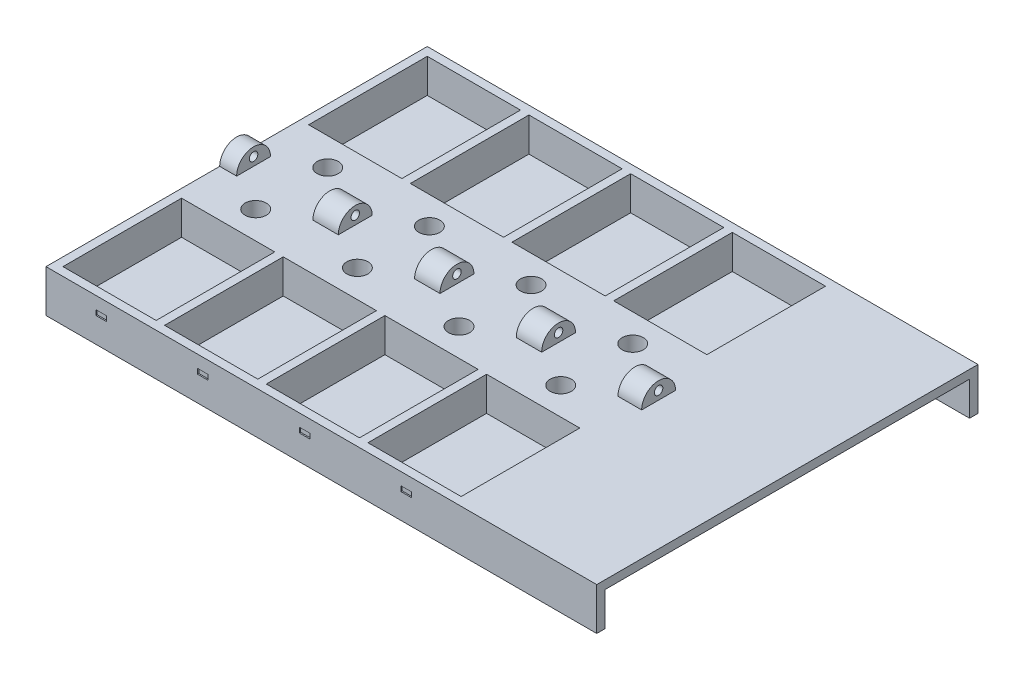
from build123d import *

# Parameters (mm, degrees)
SKETCH_1_W             = 130
SKETCH_1_H             = 90
EXTRUDE_1_DEPTH        = 10
SKETCH_2_W             = 22
SKETCH_2_H             = 28
CUT_EXTRUDE_1_DEPTH    = 8
SKETCH_3_W             = 25
SKETCH_3_H             = 6
CUT_EXTRUDE_2_DEPTH    = 131
EXTRUDE_2_DEPTH        = 130
SKETCH_7_R             = 2.5
CUT_EXTRUDE_5_DEPTH    = 9
SKETCH_5_R             = 1
CUT_EXTRUDE_6_DEPTH    = 131
CUT_EXTRUDE_8_DEPTH    = 18
PATTERN_LINEAR_1_COUNT = 4
PATTERN_LINEAR_1_PITCH = 24
CUT_EXTRUDE_9_DEPTH    = 0.5
PATTERN_LINEAR_2_COUNT = 4
PATTERN_LINEAR_2_PITCH = 24
MIRROR_1_COPY_1_DEPTH  = 0.5
MIRROR_1_COPY_2_DEPTH  = 0.5
MIRROR_1_COPY_3_DEPTH  = 0.5
SKETCH_11_W            = 86
SKETCH_11_H            = 8
CUT_EXTRUDE_10_DEPTH   = 32
SKETCH_12_W            = 30.395595504
SKETCH_12_H            = 8
CUT_EXTRUDE_11_DEPTH   = 8


with BuildPart() as part:
    # 草图1 → 凸台-拉伸1 (new body)
    with BuildSketch(Plane(origin=(0, 0, 0), x_dir=(1, 0, 0), z_dir=(0, 1, 0))):
        with Locations((65, 45)):
            Rectangle(SKETCH_1_W, SKETCH_1_H)
    extrude(amount=EXTRUDE_1_DEPTH)

    # 草图2 → 切除-拉伸1 (cut)
    with BuildSketch(Plane(origin=(0, 10, 0), x_dir=(1, 0, 0), z_dir=(0, 1, 0))):
        with Locations((13, 74)):
            Rectangle(SKETCH_2_W, SKETCH_2_H)
        with Locations((37, 74)):
            Rectangle(SKETCH_2_W, SKETCH_2_H)
        with Locations((61, 74)):
            Rectangle(SKETCH_2_W, SKETCH_2_H)
        with Locations((85, 74)):
            Rectangle(SKETCH_2_W, SKETCH_2_H)
        with Locations((37, 16)):
            Rectangle(SKETCH_2_W, SKETCH_2_H)
        with Locations((61, 16)):
            Rectangle(SKETCH_2_W, SKETCH_2_H)
        with Locations((85, 16)):
            Rectangle(SKETCH_2_W, SKETCH_2_H)
        with Locations((13, 16)):
            Rectangle(SKETCH_2_W, SKETCH_2_H)
    extrude(amount=-CUT_EXTRUDE_1_DEPTH, mode=Mode.SUBTRACT)

    # 草图3 → 切除-拉伸2 (cut, through all)
    with BuildSketch(Plane.ZY):
        with Locations((-45, 3)):
            Rectangle(SKETCH_3_W, SKETCH_3_H)
    extrude(amount=-CUT_EXTRUDE_2_DEPTH, mode=Mode.SUBTRACT)

    # 草图4 → 凸台-拉伸2 (add, through all)
    with BuildSketch(Plane.ZY):
        with BuildLine():
            Line((-49, 10), (-41, 10))
            ThreePointArc((-41, 10), (-45, 14), (-49, 10))
        make_face()
    extrude(amount=-EXTRUDE_2_DEPTH)

    # 草图7 → 切除-拉伸5 (cut, through all)
    with BuildSketch(Plane.XZ.offset(-6)):
        with Locations((13, -36.5)):
            Circle(SKETCH_7_R)
        with Locations((37, -36.5)):
            Circle(SKETCH_7_R)
        with Locations((61, -36.5)):
            Circle(SKETCH_7_R)
        with Locations((85, -36.5)):
            Circle(SKETCH_7_R)
        with Locations((85, -53.5)):
            Circle(SKETCH_7_R)
        with Locations((61, -53.5)):
            Circle(SKETCH_7_R)
        with Locations((37, -53.5)):
            Circle(SKETCH_7_R)
        with Locations((13, -53.5)):
            Circle(SKETCH_7_R)
    extrude(amount=-CUT_EXTRUDE_5_DEPTH, mode=Mode.SUBTRACT)

    # 草图5 → 切除-拉伸6 (cut, through all)
    with BuildSketch(Plane.ZY):
        with Locations((-45, 12)):
            Circle(SKETCH_5_R)
    extrude(amount=-CUT_EXTRUDE_6_DEPTH, mode=Mode.SUBTRACT)

    # 草图8 → 切除-拉伸8 (cut)
    with BuildSketch(Plane.ZY.offset(-4)):
        Polygon((-49, 10), (-49, 15.914476158), (-40.761753379, 15.914476158), (-41, 10), align=None)
    cut_extrude_8 = extrude(amount=-CUT_EXTRUDE_8_DEPTH, mode=Mode.SUBTRACT)

    # 阵列(线性)1: 切除-拉伸8 ×4
    with Locations(*[(i * PATTERN_LINEAR_1_PITCH, 0, 0) for i in range(1, PATTERN_LINEAR_1_COUNT)]):
        add(cut_extrude_8, mode=Mode.SUBTRACT)

    # 草图10 → 切除-拉伸9 (cut)
    with BuildSketch(Plane(origin=(0, 0, -90), x_dir=(-1, 0, 0), z_dir=(0, 0, -1))):
        Polygon((-12.992503856, 7.1), (-11.792503856, 7.1), (-11.792503856, 5.9), (-13.082457584, 5.9), (-14.282457584, 5.9), (-14.282457584, 7.1), align=None)
    cut_extrude_9 = extrude(amount=-CUT_EXTRUDE_9_DEPTH, mode=Mode.SUBTRACT)

    # 阵列(线性)2: 切除-拉伸9 ×4
    with Locations(*[(i * PATTERN_LINEAR_2_PITCH, 0, 0) for i in range(1, PATTERN_LINEAR_2_COUNT)]):
        add(cut_extrude_9, mode=Mode.SUBTRACT)

    # 镜向1: 切除-拉伸9 across plane
    add(cut_extrude_9.mirror(Plane.XY.offset(-44.896142346)), mode=Mode.SUBTRACT)

    # 镜向1 copy 1 sketch → 镜向1 copy 1 (cut)
    with BuildSketch(Plane(origin=(24, 0, 0.207715309), x_dir=(-1, 0, 0), z_dir=(0, 0, 1))):
        Polygon((-12.992503856, -7.1), (-11.792503856, -7.1), (-11.792503856, -5.9), (-13.082457584, -5.9), (-14.282457584, -5.9), (-14.282457584, -7.1), align=None)
    extrude(amount=-MIRROR_1_COPY_1_DEPTH, mode=Mode.SUBTRACT)

    # 镜向1 copy 2 sketch → 镜向1 copy 2 (cut)
    with BuildSketch(Plane(origin=(48, 0, 0.207715309), x_dir=(-1, 0, 0), z_dir=(0, 0, 1))):
        Polygon((-12.992503856, -7.1), (-11.792503856, -7.1), (-11.792503856, -5.9), (-13.082457584, -5.9), (-14.282457584, -5.9), (-14.282457584, -7.1), align=None)
    extrude(amount=-MIRROR_1_COPY_2_DEPTH, mode=Mode.SUBTRACT)

    # 镜向1 copy 3 sketch → 镜向1 copy 3 (cut)
    with BuildSketch(Plane(origin=(72, 0, 0.207715309), x_dir=(-1, 0, 0), z_dir=(0, 0, 1))):
        Polygon((-12.992503856, -7.1), (-11.792503856, -7.1), (-11.792503856, -5.9), (-13.082457584, -5.9), (-14.282457584, -5.9), (-14.282457584, -7.1), align=None)
    extrude(amount=-MIRROR_1_COPY_3_DEPTH, mode=Mode.SUBTRACT)

    # 草图11 → 切除-拉伸10 (cut)
    with BuildSketch(Plane(origin=(130, 0, 0), x_dir=(0, 0, -1), z_dir=(1, 0, 0))):
        with Locations((45, 4)):
            Rectangle(SKETCH_11_W, SKETCH_11_H)
    extrude(amount=-CUT_EXTRUDE_10_DEPTH, mode=Mode.SUBTRACT)

    # 草图12 → 切除-拉伸11 (cut)
    with BuildSketch(Plane(origin=(0, 10, 0), x_dir=(1, 0, 0), z_dir=(0, 1, 0))):
        with Locations((114.802202248, 45)):
            Rectangle(SKETCH_12_W, SKETCH_12_H)
    extrude(amount=CUT_EXTRUDE_11_DEPTH, mode=Mode.SUBTRACT)


solid = part.part
